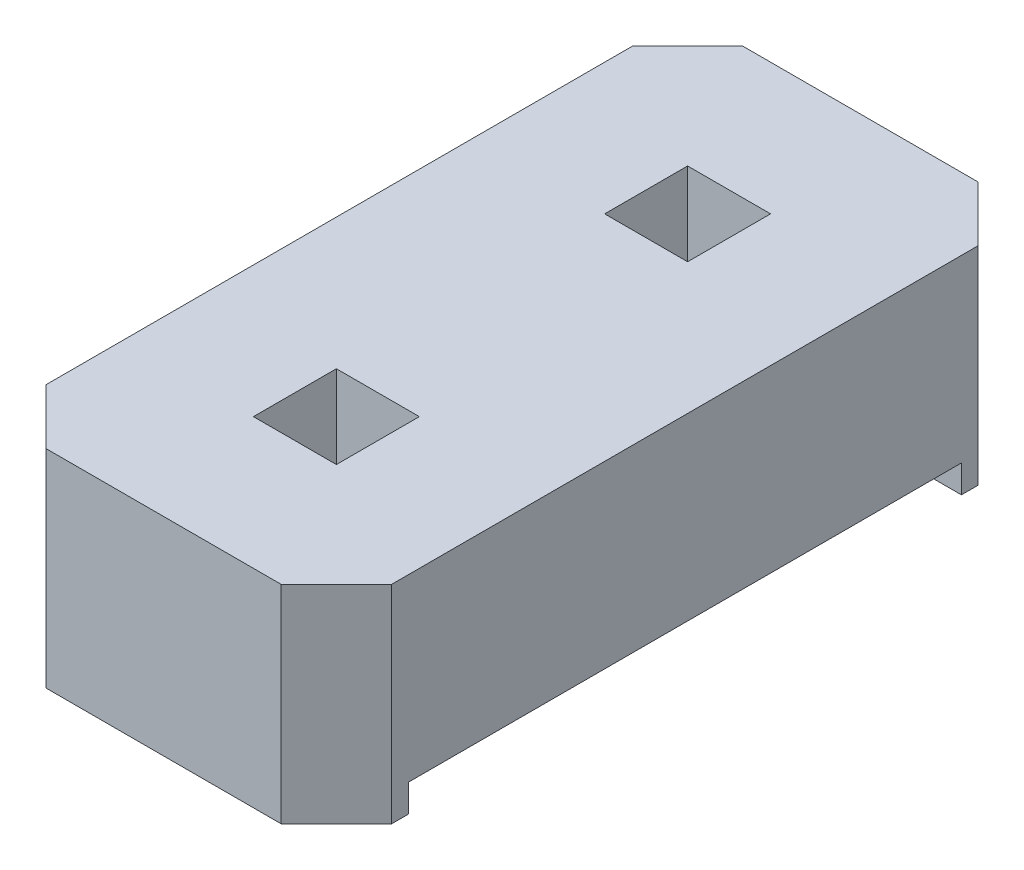
from build123d import *

# Parameters (mm, degrees)
ESQUISSE1_W             = 0.6
ESQUISSE1_H             = 0.6
BOSS_EXTRU_1_DEPTH      = 1.5
ESQUISSE2_W             = 4
ESQUISSE2_H             = 0.4
ENL_V_MAT_EXTRU_1_DEPTH = 3.5


with BuildPart() as part:
    # Esquisse1 → Boss.-Extru.1 (new body)
    with BuildSketch(Plane(origin=(0, 0, 0), x_dir=(1, 0, 0), z_dir=(0, 1, 0))):
        Polygon((-1.25, 2.12), (-0.85, 2.52), (0.85, 2.52), (1.25, 2.12), (1.25, -2.12), (0.85, -2.52), (-0.85, -2.52), (-1.25, -2.12), align=None)
        with Locations((0, -1.27)):
            Rectangle(ESQUISSE1_W, ESQUISSE1_H, mode=Mode.SUBTRACT)
        with Locations((0, 1.27)):
            Rectangle(ESQUISSE1_W, ESQUISSE1_H, mode=Mode.SUBTRACT)
    extrude(amount=BOSS_EXTRU_1_DEPTH)

    # Esquisse2 → Enlèv. mat.-Extru.1 (cut, through all)
    with BuildSketch(Plane.ZY.offset(1.25)):
        Rectangle(ESQUISSE2_W, ESQUISSE2_H)
    extrude(amount=-ENL_V_MAT_EXTRU_1_DEPTH, mode=Mode.SUBTRACT)


solid = part.part
